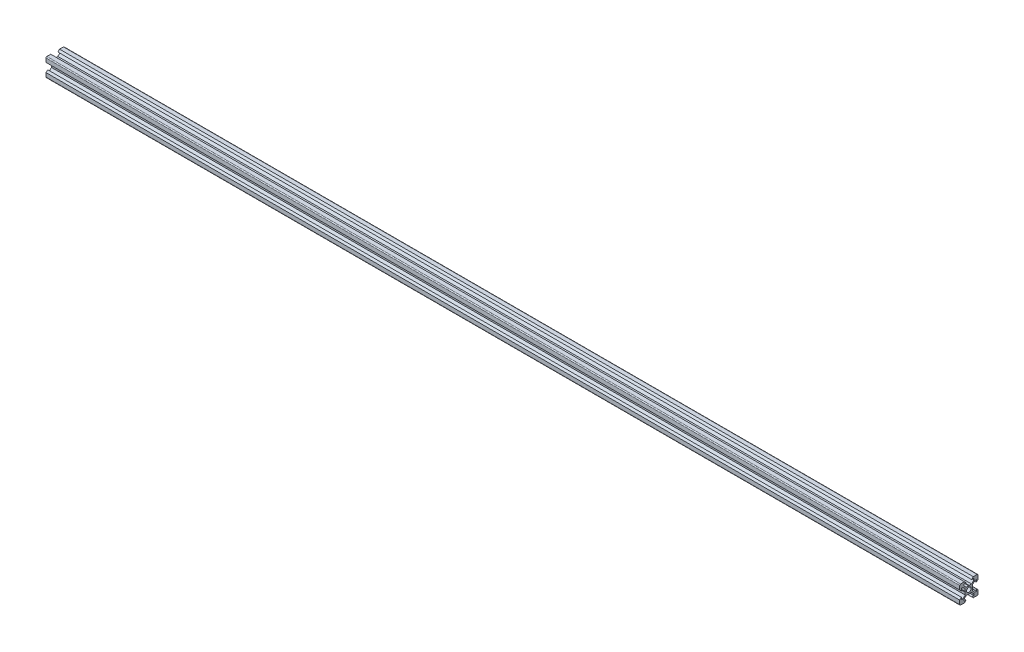
from build123d import *

# Parameters (mm, degrees)
SKETCH11_R                                  = 2.5
QUADRADO_PF20_11_PERFIL_2020_V_SLOT_1_DEPTH = 1000


with BuildPart() as part:
    # Sketch11 → Quadrado PF20-11 - PERFIL 2020 V-SLOT(1) (new body)
    with BuildSketch(Plane.YZ):
        with BuildLine():
            Line((-4.8, 10), (-3, 8.2))
            Line((-3, 8.2), (-5.5, 8.2))
            Line((-5.5, 8.2), (-5.5, 6.560660172))
            Line((-5.5, 6.560660172), (-2.939339828, 4))
            Line((-2.939339828, 4), (-0.3, 4))
            Line((-0.3, 4), (0, 3.7))
            Line((0, 3.7), (0.3, 4))
            Line((0.3, 4), (2.939339828, 4))
            Line((2.939339828, 4), (5.5, 6.560660172))
            Line((5.5, 6.560660172), (5.5, 8.2))
            Line((5.5, 8.2), (3, 8.2))
            Line((3, 8.2), (4.8, 10))
            Line((4.8, 10), (9, 10))
            ThreePointArc((9, 10), (9.707106781, 9.707106781), (10, 9))
            Line((10, 9), (10, 4.8))
            Line((10, 4.8), (8.2, 3))
            Line((8.2, 3), (8.2, 5.5))
            Line((8.2, 5.5), (6.560660172, 5.5))
            Line((6.560660172, 5.5), (4, 2.939339828))
            Line((4, 2.939339828), (4, 0.3))
            Line((4, 0.3), (3.7, 0))
            Line((3.7, 0), (4, -0.3))
            Line((4, -0.3), (4, -2.939339828))
            Line((4, -2.939339828), (6.560660172, -5.5))
            Line((6.560660172, -5.5), (8.2, -5.5))
            Line((8.2, -5.5), (8.2, -3))
            Line((8.2, -3), (10, -4.8))
            Line((10, -4.8), (10, -9))
            ThreePointArc((10, -9), (9.707106781, -9.707106781), (9, -10))
            Line((9, -10), (4.8, -10))
            Line((4.8, -10), (3, -8.2))
            Line((3, -8.2), (5.5, -8.2))
            Line((5.5, -8.2), (5.5, -6.560660172))
            Line((5.5, -6.560660172), (2.939339828, -4))
            Line((2.939339828, -4), (0.3, -4))
            Line((0.3, -4), (0, -3.7))
            Line((0, -3.7), (-0.3, -4))
            Line((-0.3, -4), (-2.939339828, -4))
            Line((-2.939339828, -4), (-5.5, -6.560660172))
            Line((-5.5, -6.560660172), (-5.5, -8.2))
            Line((-5.5, -8.2), (-3, -8.2))
            Line((-3, -8.2), (-4.8, -10))
            Line((-4.8, -10), (-9, -10))
            ThreePointArc((-9, -10), (-9.707106781, -9.707106781), (-10, -9))
            Line((-10, -9), (-10, -4.8))
            Line((-10, -4.8), (-8.2, -3))
            Line((-8.2, -3), (-8.2, -5.5))
            Line((-8.2, -5.5), (-6.560660172, -5.5))
            Line((-6.560660172, -5.5), (-4, -2.939339828))
            Line((-4, -2.939339828), (-4, -0.3))
            Line((-4, -0.3), (-3.7, 0))
            Line((-3.7, 0), (-4, 0.3))
            Line((-4, 0.3), (-4, 2.939339828))
            Line((-4, 2.939339828), (-6.560660172, 5.5))
            Line((-6.560660172, 5.5), (-8.2, 5.5))
            Line((-8.2, 5.5), (-8.2, 3))
            Line((-8.2, 3), (-10, 4.8))
            Line((-10, 4.8), (-10, 9))
            ThreePointArc((-10, 9), (-9.707106781, 9.707106781), (-9, 10))
            Line((-9, 10), (-4.8, 10))
        make_face()
        Circle(SKETCH11_R, mode=Mode.SUBTRACT)
    extrude(amount=QUADRADO_PF20_11_PERFIL_2020_V_SLOT_1_DEPTH)


solid = part.part
